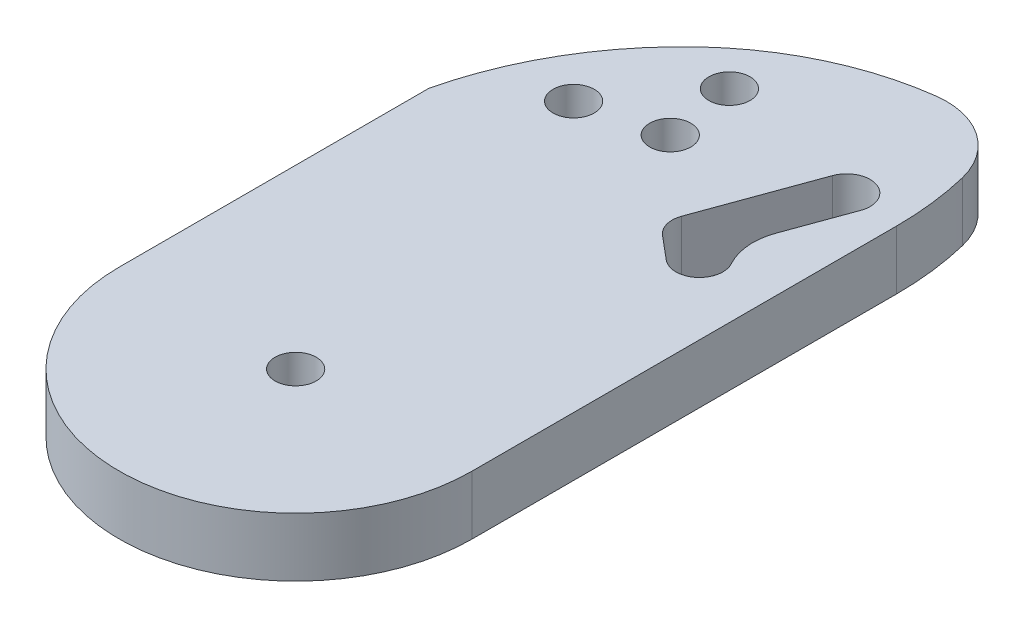
from build123d import *

# Parameters (mm, degrees)
SKETCH1_R           = 1.75
BOSS_EXTRUDE1_DEPTH = 5
FILLET1_R           = 5
CUT_EXTRUDE1_DEPTH  = 10
SKETCH3_R           = 1.75
CUT_EXTRUDE2_DEPTH  = 10


with BuildPart() as part:
    # Sketch1 → Boss-Extrude1 (new body)
    with BuildSketch(Plane(origin=(0, 0, 0), x_dir=(1, 0, 0), z_dir=(0, 1, 0))):
        with BuildLine():
            Line((-15, 0), (-15, 50))
            ThreePointArc((-15, 50), (0, 65), (15, 50))
            Line((15, 50), (15, 0))
            ThreePointArc((15, 0), (0, -15), (-15, 0))
        make_face()
        Circle(SKETCH1_R, mode=Mode.SUBTRACT)
        with BuildLine():
            Line((12.324500118, 35.6706981), (9.383268849, 27.589731606))
            Line((9.383268849, 27.589731606), (10.285575219, 26.832606664))
            ThreePointArc((10.285575219, 26.832606664), (10.532088886, 24.014942558), (7.714424781, 23.768428891))
            Line((7.714424781, 23.768428891), (5.739338223, 25.425723293))
            ThreePointArc((5.739338223, 25.425723293), (5.09306179, 26.440174089), (5.145528201, 27.641852466))
            Line((5.145528201, 27.641852466), (8.565729634, 37.038778674))
            ThreePointArc((8.565729634, 37.038778674), (11.129155163, 38.234123628), (12.324500118, 35.6706981))
        make_face(mode=Mode.SUBTRACT)
    extrude(amount=BOSS_EXTRUDE1_DEPTH)

    # Fillet1
    fillet1_edges = [part.edges().sort_by_distance(p)[0] for p in [
        (9.383268849, 2.5, -27.589731606),
    ]]
    fillet(fillet1_edges, radius=FILLET1_R)

    # Sketch2 → Cut-Extrude1 (cut)
    with BuildSketch(Plane(origin=(0, 5, 0), x_dir=(1, 0, 0), z_dir=(0, 1, 0))):
        with BuildLine():
            Line((-15, 26.324644949), (-40.925594741, 69.238213195))
            Line((-40.925594741, 69.238213195), (-58.771967888, 111.080687023))
            Line((-58.771967888, 111.080687023), (39.28439299, 102.825794629))
            Line((39.28439299, 102.825794629), (15, 36.046990739))
            ThreePointArc((15, 36.046990739), (14.81014445, 39.245839168), (14.243243524, 42.399773179))
            ThreePointArc((14.243243524, 42.399773179), (11.621838426, 46.208407589), (7.127072402, 47.292169164))
            ThreePointArc((7.127072402, 47.292169164), (-0.175202385, 45.163669538), (-6.484026655, 40.9148504))
            ThreePointArc((-6.484026655, 40.9148504), (-11.826766868, 34.252893813), (-15, 26.324644949))
        make_face()
    extrude(amount=-CUT_EXTRUDE1_DEPTH, mode=Mode.SUBTRACT)

    # Sketch3 → Cut-Extrude2 (cut)
    with BuildSketch(Plane(origin=(0, 5, 0), x_dir=(1, 0, 0), z_dir=(0, 1, 0))):
        with Locations((-1.301778952, 33.126107378)):
            Circle(SKETCH3_R)
        with Locations((-2.207127715, 39.057409395)):
            Circle(SKETCH3_R)
        with Locations((-7.905919506, 31.519764857)):
            Circle(SKETCH3_R)
    extrude(amount=-CUT_EXTRUDE2_DEPTH, mode=Mode.SUBTRACT)


solid = part.part
